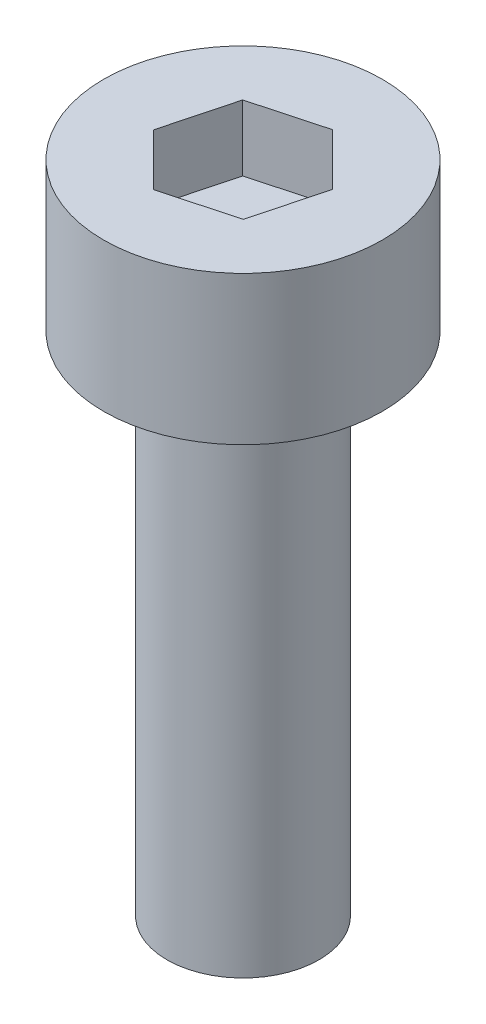
from build123d import *

# Parameters (mm, degrees)
SKETCH_1_R          = 1.5
EXTRUDE_1_DEPTH     = 10
SKETCH_2_R          = 2.75
EXTRUDE_2_DEPTH     = 2.93
CUT_EXTRUDE_1_DEPTH = 1.3


with BuildPart() as part:
    # 草图1 → 凸台-拉伸1 (new body)
    with BuildSketch(Plane(origin=(0, 0, 0), x_dir=(1, 0, 0), z_dir=(0, 1, 0))):
        Circle(SKETCH_1_R)
    extrude(amount=EXTRUDE_1_DEPTH)

    # 草图2 → 凸台-拉伸2 (add)
    with BuildSketch(Plane(origin=(0, 10, 0), x_dir=(1, 0, 0), z_dir=(0, 1, 0))):
        Circle(SKETCH_2_R)
    extrude(amount=EXTRUDE_2_DEPTH)

    # 草图3 → 切除-拉伸1 (cut)
    with BuildSketch(Plane(origin=(0, 12.93, 0), x_dir=(1, 0, 0), z_dir=(0, 1, 0))):
        Polygon((1.024005842, -1.017224346), (1.392945046, 0.378202899), (0.368939204, 1.395427245), (-1.024005842, 1.017224346), (-1.392945046, -0.378202899), (-0.368939204, -1.395427245), align=None)
    extrude(amount=-CUT_EXTRUDE_1_DEPTH, mode=Mode.SUBTRACT)


solid = part.part
